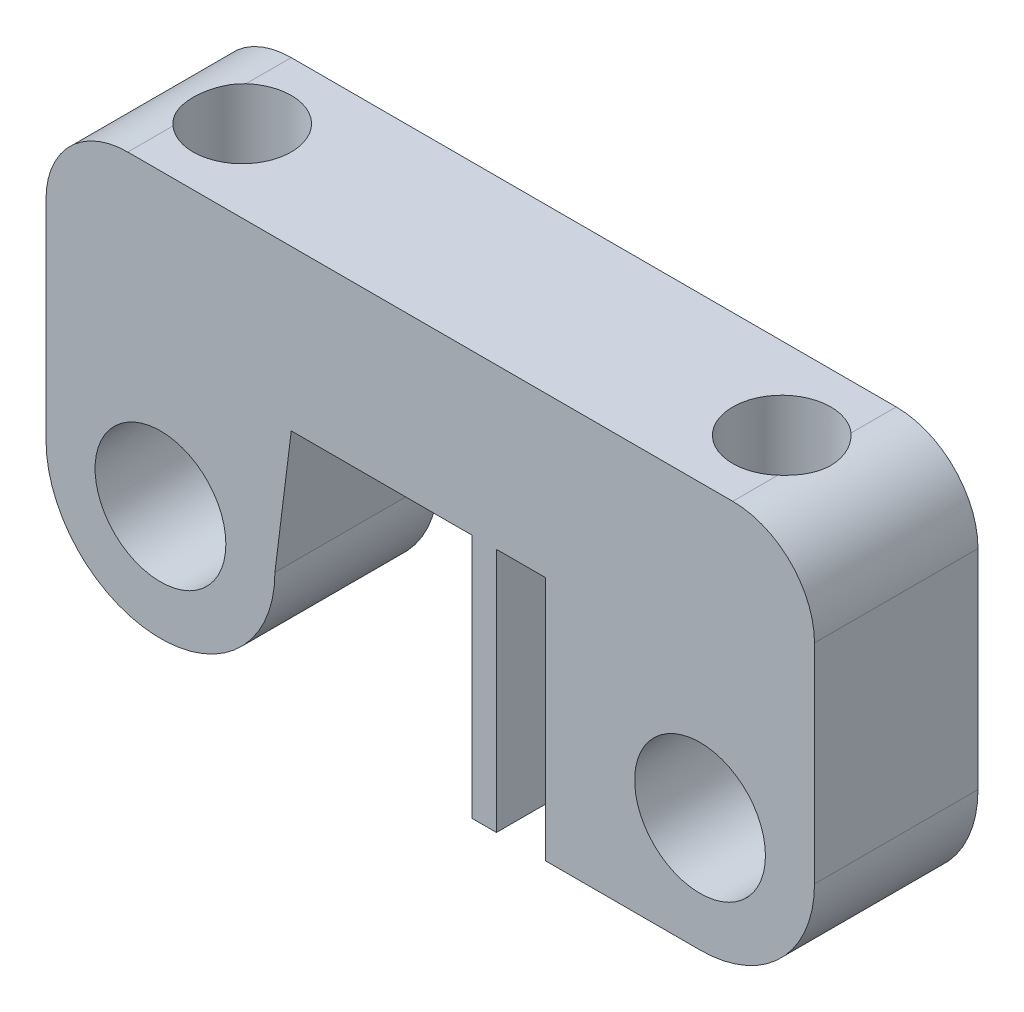
from build123d import *

# Parameters (mm, degrees)
ESBO_O1_R                = 4
RESSALTO_EXTRUS_O1_DEPTH = 10
ESBO_O2_R                = 1
CORTE_EXTRUS_O1_DEPTH    = 10
ESBO_O3_R                = 1
CORTE_EXTRUS_O2_DEPTH    = 20
ESBO_O5_R                = 3
CORTE_EXTRUS_O3_DEPTH    = 6


with BuildPart() as part:
    # Esboço1 → Ressalto-extrusão1 (new body)
    with BuildSketch(Plane.XY):
        with BuildLine():
            Line((-23.5, 0), (-23.5, 12.766875201))
            ThreePointArc((-23.5, 12.766875201), (-22.035533906, 16.302409107), (-18.5, 17.766875201))
            Line((-18.5, 17.766875201), (18.5, 17.766875201))
            ThreePointArc((18.5, 17.766875201), (22.035533906, 16.302409107), (23.5, 12.766875201))
            Line((23.5, 12.766875201), (23.5, 0))
            ThreePointArc((23.5, 0), (21.449747468, -4.949747468), (16.5, -7))
            Line((16.5, -7), (7.047816286, -7))
            Line((7.047816286, -7), (7.047816286, 8))
            Line((7.047816286, 8), (4.047816286, 8))
            Line((4.047816286, 8), (4.047816286, -7))
            Line((4.047816286, -7), (2.547816286, -7))
            Line((2.547816286, -7), (2.547816286, 8))
            Line((2.547816286, 8), (-8.5, 8))
            Line((-8.5, 8), (-9.5, 0))
            ThreePointArc((-9.5, 0), (-16.5, -7), (-23.5, 0))
        make_face()
        with Locations((-16.5, 0)):
            Circle(ESBO_O1_R, mode=Mode.SUBTRACT)
        with Locations((16.5, 0)):
            Circle(ESBO_O1_R, mode=Mode.SUBTRACT)
    extrude(amount=RESSALTO_EXTRUS_O1_DEPTH)

    # Esboço2 → Corte-extrusão1 (cut, along a direction that is not the sketch's normal)
    with BuildSketch(Plane.ZY.offset(-2.547816286)):
        with Locations((5, -5.228639013)):
            Circle(ESBO_O2_R)
    extrude(amount=-CORTE_EXTRUS_O1_DEPTH, dir=(-0.931482298, -0.363786654, 0), mode=Mode.SUBTRACT)

    # Esboço3 → Corte-extrusão2 (cut)
    with BuildSketch(Plane(origin=(0, 17.766875201, 0), x_dir=(1, 0, 0), z_dir=(0, 1, 0))):
        with Locations((-16.5, -5)):
            Circle(ESBO_O3_R)
        with Locations((16.5, -5)):
            Circle(ESBO_O3_R)
    extrude(amount=-CORTE_EXTRUS_O2_DEPTH, mode=Mode.SUBTRACT)

    # Esboço5 → Corte-extrusão3 (cut)
    with BuildSketch(Plane(origin=(0, 17.766875201, 0), x_dir=(1, 0, 0), z_dir=(0, 1, 0))):
        with Locations((-16.5, -5)):
            Circle(ESBO_O5_R)
        with Locations((16.5, -5)):
            Circle(ESBO_O5_R)
    extrude(amount=-CORTE_EXTRUS_O3_DEPTH, mode=Mode.SUBTRACT)


solid = part.part
